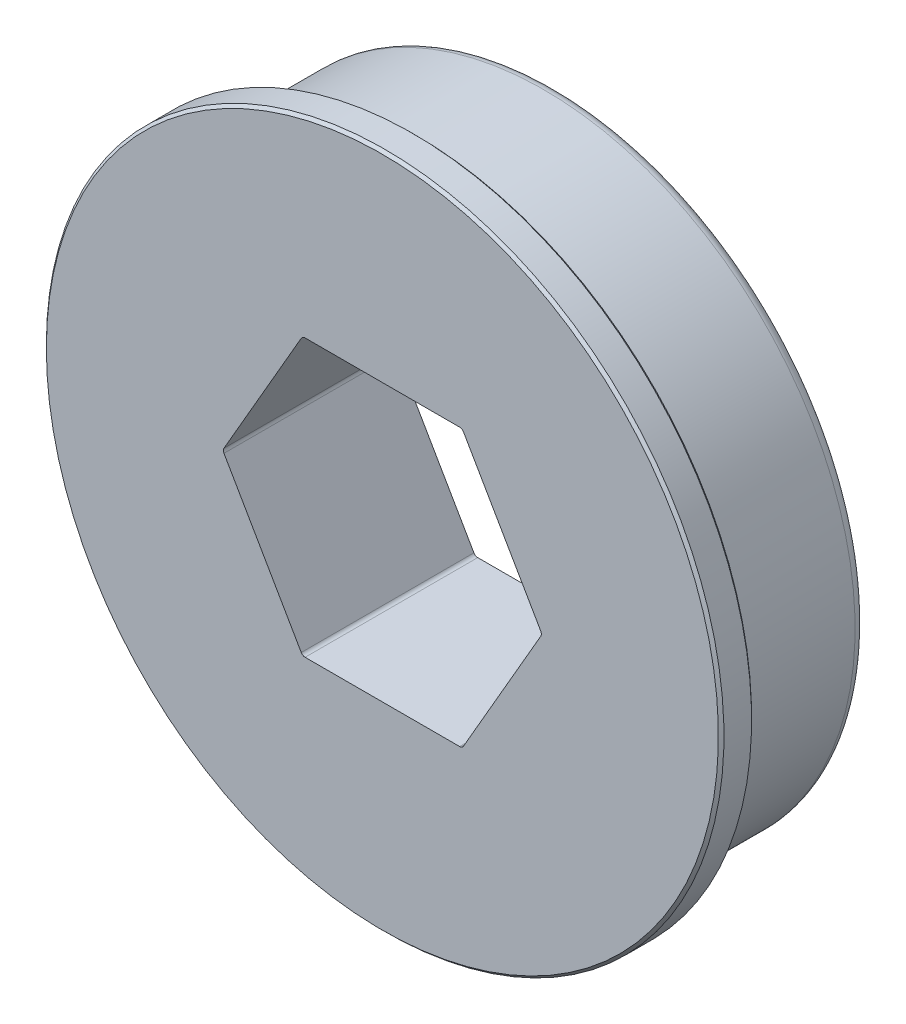
from build123d import *

# Parameters (mm, degrees)
CUT_EXTRUDE1_DEPTH = 8.92734
CHAMFER1_SIZE      = 0.127
FILLET1_R          = 0.2032
FILLET2_R          = 0.508


with BuildPart() as part:
    # Sketch1 → Revolve1 (revolve)
    with BuildSketch(Plane.XZ):
        Polygon((15.4305, 7.92734), (0, 7.92734), (0, 0), (14.2875, 0), (14.2875, 5.89534), (13.97, 5.89534), (13.97, 6.40334), (15.5575, 6.40334), (15.5575, 7.80034), align=None)
    revolve(axis=Axis((0, 0, 7.92734), (0, 0, -1)))

    # Sketch2 → Cut-Extrude1 (cut, through all)
    with BuildSketch(Plane.XY.offset(7.92734)):
        Polygon((3.666174209, -6.35), (7.332348419, 0), (3.666174209, 6.35), (-3.666174209, 6.35), (-7.332348419, 0), (-3.666174209, -6.35), align=None)
    extrude(amount=-CUT_EXTRUDE1_DEPTH, mode=Mode.SUBTRACT)

    # Chamfer1
    chamfer1_edges = [part.edges().sort_by_distance(p)[0] for p in [
        (-15.5575, 0, 6.40334),
    ]]
    chamfer(chamfer1_edges, length=CHAMFER1_SIZE)

    # Fillet1
    fillet1_edges = [part.edges().sort_by_distance(p)[0] for p in [
        (3.666174209, -6.35, 3.96367),
        (-3.666174209, -6.35, 3.96367),
        (-7.332348419, 0, 3.96367),
        (-3.666174209, 6.35, 3.96367),
        (3.666174209, 6.35, 3.96367),
        (7.332348419, 0, 3.96367),
    ]]
    fillet(fillet1_edges, radius=FILLET1_R)

    # Fillet2
    fillet2_edges = [part.edges().sort_by_distance(p)[0] for p in [
        (-14.2875, 0, 0),
    ]]
    fillet(fillet2_edges, radius=FILLET2_R)


solid = part.part
